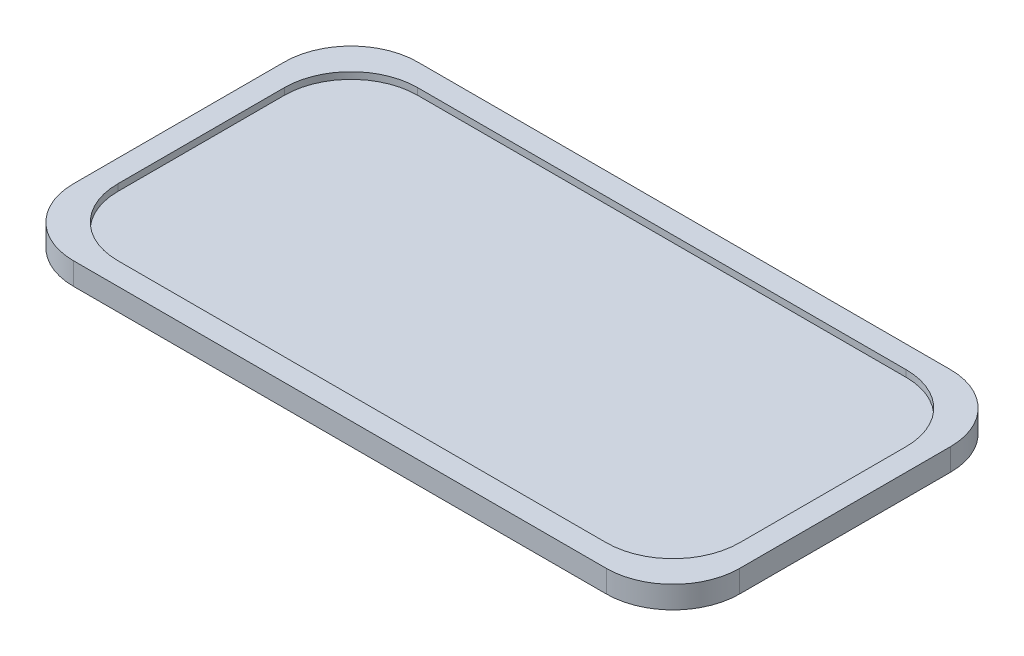
from build123d import *

# Parameters (mm, degrees)
BOSS_EXTRUDE1_DEPTH = 10
CUT_EXTRUDE1_DEPTH  = 5
CUT_EXTRUDE2_DEPTH  = 3


with BuildPart() as part:
    # Sketch1 → Boss-Extrude1 (new body)
    with BuildSketch(Plane(origin=(0, 0, 0), x_dir=(1, 0, 0), z_dir=(0, 1, 0))):
        with BuildLine():
            Line((-120, 77.5), (120, 77.5))
            ThreePointArc((120, 77.5), (141.213203436, 68.713203436), (150, 47.5))
            Line((150, 47.5), (150, -47.5))
            ThreePointArc((150, -47.5), (141.213203436, -68.713203436), (120, -77.5))
            Line((120, -77.5), (-120, -77.5))
            ThreePointArc((-120, -77.5), (-141.213203436, -68.713203436), (-150, -47.5))
            Line((-150, -47.5), (-150, 47.5))
            ThreePointArc((-150, 47.5), (-141.213203436, 68.713203436), (-120, 77.5))
        make_face()
    extrude(amount=BOSS_EXTRUDE1_DEPTH)

    # Sketch2 → Cut-Extrude1 (cut)
    with BuildSketch(Plane.XZ):
        with BuildLine():
            Line((-110, 73.5), (110, 73.5))
            ThreePointArc((110, 73.5), (135.455844123, 62.955844123), (146, 37.5))
            Line((146, 37.5), (146, -37.5))
            ThreePointArc((146, -37.5), (135.455844123, -62.955844123), (110, -73.5))
            Line((110, -73.5), (-110, -73.5))
            ThreePointArc((-110, -73.5), (-135.455844123, -62.955844123), (-146, -37.5))
            Line((-146, -37.5), (-146, 37.5))
            ThreePointArc((-146, 37.5), (-135.455844123, 62.955844123), (-110, 73.5))
        make_face()
        with BuildLine():
            Line((-110, 67.5), (110, 67.5))
            ThreePointArc((110, 67.5), (131.213203436, 58.713203436), (140, 37.5))
            Line((140, 37.5), (140, -37.5))
            ThreePointArc((140, -37.5), (131.213203436, -58.713203436), (110, -67.5))
            Line((110, -67.5), (-110, -67.5))
            ThreePointArc((-110, -67.5), (-131.213203436, -58.713203436), (-140, -37.5))
            Line((-140, -37.5), (-140, 37.5))
            ThreePointArc((-140, 37.5), (-131.213203436, 58.713203436), (-110, 67.5))
        make_face(mode=Mode.SUBTRACT)
    extrude(amount=-CUT_EXTRUDE1_DEPTH, mode=Mode.SUBTRACT)

    # Sketch3 → Cut-Extrude2 (cut)
    with BuildSketch(Plane(origin=(0, 10, 0), x_dir=(1, 0, 0), z_dir=(0, 1, 0))):
        with BuildLine():
            Line((-110, 67.5), (110, 67.5))
            ThreePointArc((110, 67.5), (131.213203436, 58.713203436), (140, 37.5))
            Line((140, 37.5), (140, -37.5))
            ThreePointArc((140, -37.5), (131.213203436, -58.713203436), (110, -67.5))
            Line((110, -67.5), (-110, -67.5))
            ThreePointArc((-110, -67.5), (-131.213203436, -58.713203436), (-140, -37.5))
            Line((-140, -37.5), (-140, 37.5))
            ThreePointArc((-140, 37.5), (-131.213203436, 58.713203436), (-110, 67.5))
        make_face()
    extrude(amount=-CUT_EXTRUDE2_DEPTH, mode=Mode.SUBTRACT)


solid = part.part
